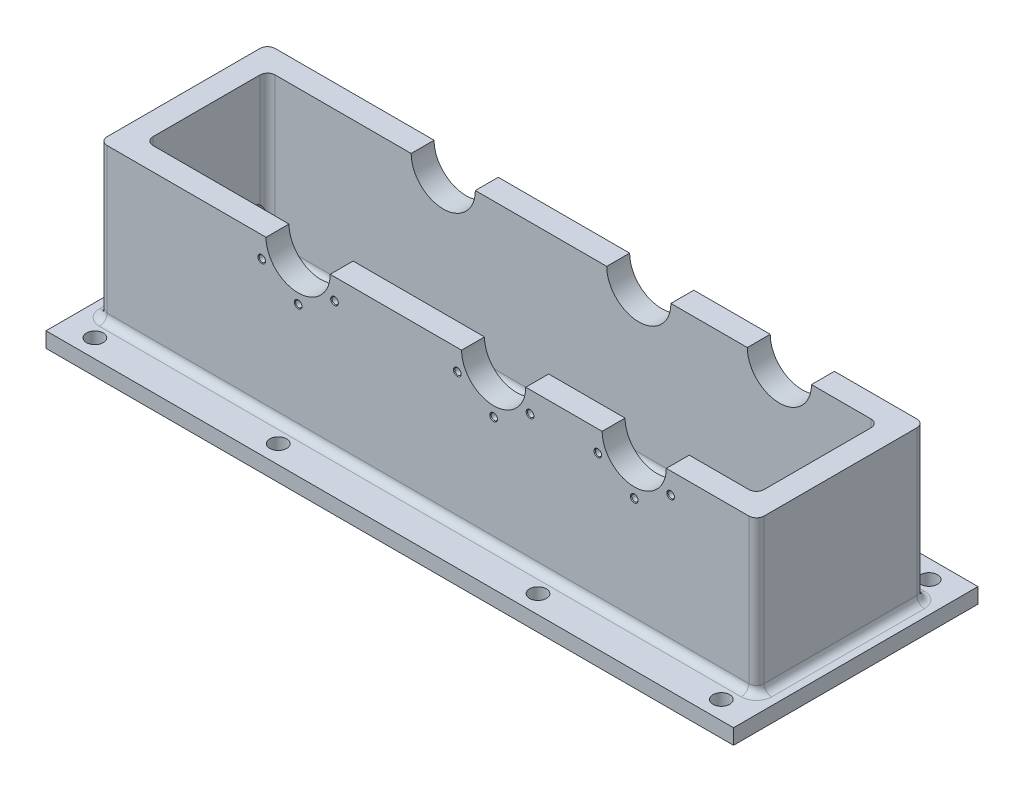
from build123d import *

# Parameters (mm, degrees)
SKETCH1_W           = 450
SKETCH1_H           = 160
BOSS_EXTRUDE1_DEPTH = 10
SKETCH2_W           = 430
SKETCH2_H           = 110
SKETCH2_W_2         = 400
SKETCH2_H_2         = 80
BOSS_EXTRUDE2_DEPTH = 100
SKETCH3_R           = 5.5
CUT_EXTRUDE1_DEPTH  = 100
SKETCH4_R           = 21
CUT_EXTRUDE2_DEPTH  = 136
CIRPATTERN1_COUNT   = 6
CIRPATTERN2_COUNT   = 6
CIRPATTERN3_COUNT   = 6
FILLET1_R           = 5
SKETCH13_R          = 8
CUT_EXTRUDE3_DEPTH  = 100


with BuildPart() as part:
    # Sketch1 → Boss-Extrude1 (new body)
    with BuildSketch(Plane(origin=(0, 0, 0), x_dir=(1, 0, 0), z_dir=(0, 1, 0))):
        Rectangle(SKETCH1_W, SKETCH1_H)
    extrude(amount=BOSS_EXTRUDE1_DEPTH)

    # Sketch2 → Boss-Extrude2 (add)
    with BuildSketch(Plane(origin=(0, 10, 0), x_dir=(1, 0, 0), z_dir=(0, 1, 0))):
        Rectangle(SKETCH2_W, SKETCH2_H)
        Rectangle(SKETCH2_W_2, SKETCH2_H_2, mode=Mode.SUBTRACT)
    extrude(amount=BOSS_EXTRUDE2_DEPTH)

    # Sketch3 → Cut-Extrude1 (cut)
    with BuildSketch(Plane(origin=(0, 10, 0), x_dir=(1, 0, 0), z_dir=(0, 1, 0))):
        with Locations((-205, 68)):
            Circle(SKETCH3_R)
        with Locations((-85, 68)):
            Circle(SKETCH3_R)
        with Locations((-205, -68)):
            Circle(SKETCH3_R)
        with Locations((-85, -68)):
            Circle(SKETCH3_R)
        with Locations((205, 68)):
            Circle(SKETCH3_R)
        with Locations((85, 68)):
            Circle(SKETCH3_R)
        with Locations((85, -68)):
            Circle(SKETCH3_R)
        with Locations((205, -68)):
            Circle(SKETCH3_R)
    extrude(amount=-CUT_EXTRUDE1_DEPTH, mode=Mode.SUBTRACT)

    # Sketch4 → Cut-Extrude2 (cut, through all)
    with BuildSketch(Plane.XY.offset(55)):
        with Locations((-85, 110)):
            Circle(SKETCH4_R)
        with Locations((43, 110)):
            Circle(SKETCH4_R)
        with Locations((135, 110)):
            Circle(SKETCH4_R)
    extrude(amount=-CUT_EXTRUDE2_DEPTH, mode=Mode.SUBTRACT)

    # Sketch10 → M5 Tapped Hole1 (revolve, cut)
    with BuildSketch(Plane(origin=(158.815698604, 96.25, 55), x_dir=(0, -1, 0), z_dir=(1, 0, 0))):
        Polygon((0, 0), (0, 13.6618073), (2.1, 12.4), (2.1, 0.425), (2.525, 0), align=None)
    m5_tapped_hole1 = revolve(axis=Axis((158.815698604, 96.25, 61.35), (0, 0, -1)), mode=Mode.SUBTRACT)

    # Sketch11 → M5 Tapped Hole2 (revolve, cut)
    with BuildSketch(Plane(origin=(66.815698604, 96.25, 55), x_dir=(0, -1, 0), z_dir=(1, 0, 0))):
        Polygon((0, 0), (0, 13.6618073), (2.1, 12.4), (2.1, 0.425), (2.525, 0), align=None)
    m5_tapped_hole2 = revolve(axis=Axis((66.815698604, 96.25, 61.35), (0, 0, -1)), mode=Mode.SUBTRACT)

    # Sketch12 → M5 Tapped Hole3 (revolve, cut)
    with BuildSketch(Plane(origin=(-61.184301396, 96.25, 55), x_dir=(0, -1, 0), z_dir=(1, 0, 0))):
        Polygon((0, 0), (0, 13.6618073), (2.1, 12.4), (2.1, 0.425), (2.525, 0), align=None)
    m5_tapped_hole3 = revolve(axis=Axis((-61.184301396, 96.25, 61.35), (0, 0, -1)), mode=Mode.SUBTRACT)

    # CirPattern1: M5 Tapped Hole1 ×6 about axis, 3 skipped
    cirpattern1_axis = Axis((135, 110, -80), (0, 0, 1))
    add([m5_tapped_hole1.rotate(cirpattern1_axis, i * 360 / CIRPATTERN1_COUNT) for i in range(1, CIRPATTERN1_COUNT) if i not in (1, 2, 3)], mode=Mode.SUBTRACT)

    # CirPattern2: M5 Tapped Hole2 ×6 about axis, 3 skipped
    cirpattern2_axis = Axis((43, 110, -80), (0, 0, 1))
    add([m5_tapped_hole2.rotate(cirpattern2_axis, i * 360 / CIRPATTERN2_COUNT) for i in range(1, CIRPATTERN2_COUNT) if i not in (1, 2, 3)], mode=Mode.SUBTRACT)

    # CirPattern3: M5 Tapped Hole3 ×6 about axis, 3 skipped
    cirpattern3_axis = Axis((-85, 110, -80), (0, 0, 1))
    add([m5_tapped_hole3.rotate(cirpattern3_axis, i * 360 / CIRPATTERN3_COUNT) for i in range(1, CIRPATTERN3_COUNT) if i not in (1, 2, 3)], mode=Mode.SUBTRACT)

    # Mirror3: M5 Tapped Hole1, M5 Tapped Hole2, M5 Tapped Hole3 across plane
    add(m5_tapped_hole1.mirror(Plane.XY), mode=Mode.SUBTRACT)
    add(m5_tapped_hole2.mirror(Plane.XY), mode=Mode.SUBTRACT)
    add(m5_tapped_hole3.mirror(Plane.XY), mode=Mode.SUBTRACT)

    # Mirror3 copy 1 sketch → Mirror3 copy 1 (revolve, cut)
    with BuildSketch(Plane(origin=(111.184301396, 96.25, -55), x_dir=(-0.866025404, 0.5, 0), z_dir=(-0.5, -0.866025404, 0))):
        Polygon((0, 0), (0, -13.6618073), (2.1, -12.4), (2.1, -0.425), (2.525, 0), align=None)
    revolve(axis=Axis((111.184301396, 96.25, -61.35), (0, 0, -1)), mode=Mode.SUBTRACT)

    # Mirror3 copy 2 sketch → Mirror3 copy 2 (revolve, cut)
    with BuildSketch(Plane(origin=(135, 82.5, -55), x_dir=(-0.866025404, -0.5, 0), z_dir=(0.5, -0.866025404, 0))):
        Polygon((0, 0), (0, -13.6618073), (2.1, -12.4), (2.1, -0.425), (2.525, 0), align=None)
    revolve(axis=Axis((135, 82.5, -61.35), (0, 0, -1)), mode=Mode.SUBTRACT)

    # Mirror3 copy 3 sketch → Mirror3 copy 3 (revolve, cut)
    with BuildSketch(Plane(origin=(19.184301396, 96.25, -55), x_dir=(-0.866025404, 0.5, 0), z_dir=(-0.5, -0.866025404, 0))):
        Polygon((0, 0), (0, -13.6618073), (2.1, -12.4), (2.1, -0.425), (2.525, 0), align=None)
    revolve(axis=Axis((19.184301396, 96.25, -61.35), (0, 0, -1)), mode=Mode.SUBTRACT)

    # Mirror3 copy 4 sketch → Mirror3 copy 4 (revolve, cut)
    with BuildSketch(Plane(origin=(43, 82.5, -55), x_dir=(-0.866025404, -0.5, 0), z_dir=(0.5, -0.866025404, 0))):
        Polygon((0, 0), (0, -13.6618073), (2.1, -12.4), (2.1, -0.425), (2.525, 0), align=None)
    revolve(axis=Axis((43, 82.5, -61.35), (0, 0, -1)), mode=Mode.SUBTRACT)

    # Mirror3 copy 5 sketch → Mirror3 copy 5 (revolve, cut)
    with BuildSketch(Plane(origin=(-108.815698604, 96.25, -55), x_dir=(-0.866025404, 0.5, 0), z_dir=(-0.5, -0.866025404, 0))):
        Polygon((0, 0), (0, -13.6618073), (2.1, -12.4), (2.1, -0.425), (2.525, 0), align=None)
    revolve(axis=Axis((-108.815698604, 96.25, -61.35), (0, 0, -1)), mode=Mode.SUBTRACT)

    # Mirror3 copy 6 sketch → Mirror3 copy 6 (revolve, cut)
    with BuildSketch(Plane(origin=(-85, 82.5, -55), x_dir=(-0.866025404, -0.5, 0), z_dir=(0.5, -0.866025404, 0))):
        Polygon((0, 0), (0, -13.6618073), (2.1, -12.4), (2.1, -0.425), (2.525, 0), align=None)
    revolve(axis=Axis((-85, 82.5, -61.35), (0, 0, -1)), mode=Mode.SUBTRACT)

    # Fillet1
    fillet1_edges = [part.edges().sort_by_distance(p)[0] for p in [
        (0, 10, 40),
        (200, 10, 0),
        (0, 10, -40),
        (-200, 10, 0),
        (215, 10, 0),
        (215, 60, 55),
        (0, 10, -55),
        (215, 60, -55),
        (-215, 10, 0),
        (-215, 60, -55),
        (0, 10, 55),
        (-215, 60, 55),
        (200, 60, -40),
        (-200, 60, -40),
        (-200, 60, 40),
        (200, 60, 40),
    ]]
    fillet(fillet1_edges, radius=FILLET1_R)

    # Sketch13 → Cut-Extrude3 (cut)
    with BuildSketch(Plane.ZY.offset(215)):
        with Locations((-30, 30)):
            Circle(SKETCH13_R)
    extrude(amount=-CUT_EXTRUDE3_DEPTH, mode=Mode.SUBTRACT)


solid = part.part
